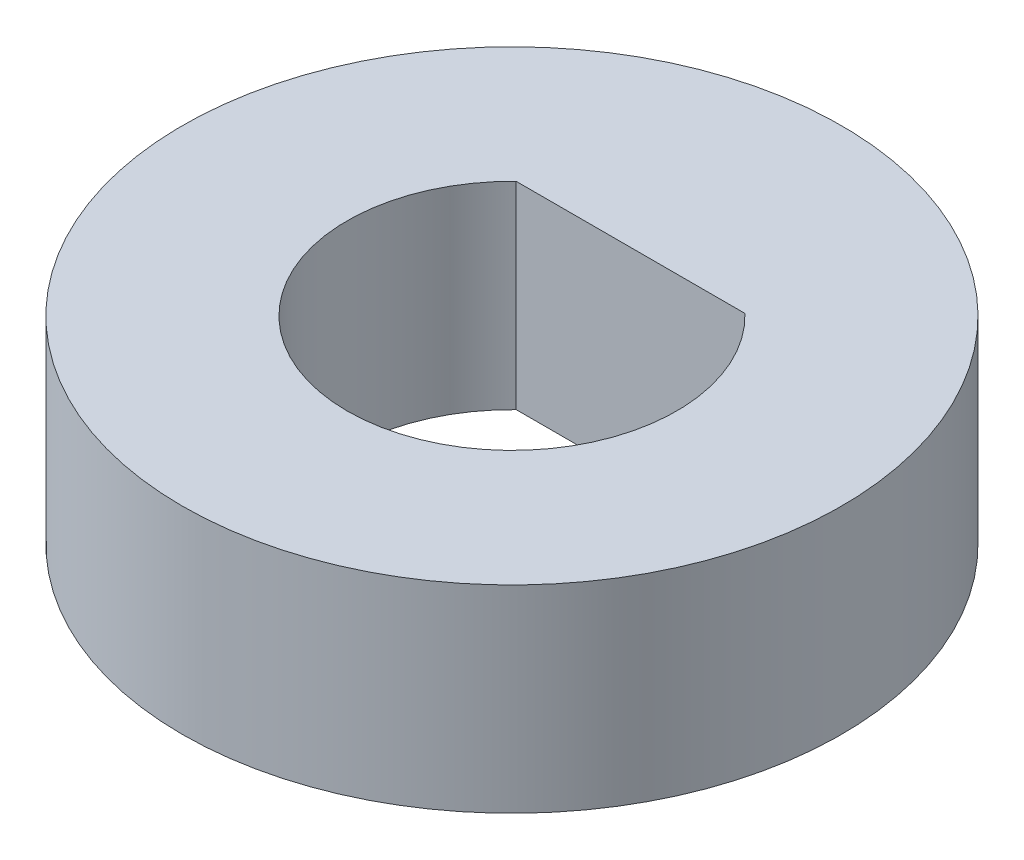
from build123d import *

# Parameters (mm, degrees)
SKETCH_1_R      = 10
EXTRUDE_1_DEPTH = 6


with BuildPart() as part:
    # 草图1 → 凸台-拉伸1 (new body)
    with BuildSketch(Plane(origin=(0, 0, 0), x_dir=(1, 0, 0), z_dir=(0, 1, 0))):
        Circle(SKETCH_1_R)
        with BuildLine():
            Line((-3.469870315, 3.6), (3.469870315, 3.6))
            ThreePointArc((3.469870315, 3.6), (0, -5), (-3.469870315, 3.6))
        make_face(mode=Mode.SUBTRACT)
    extrude(amount=EXTRUDE_1_DEPTH)


solid = part.part
